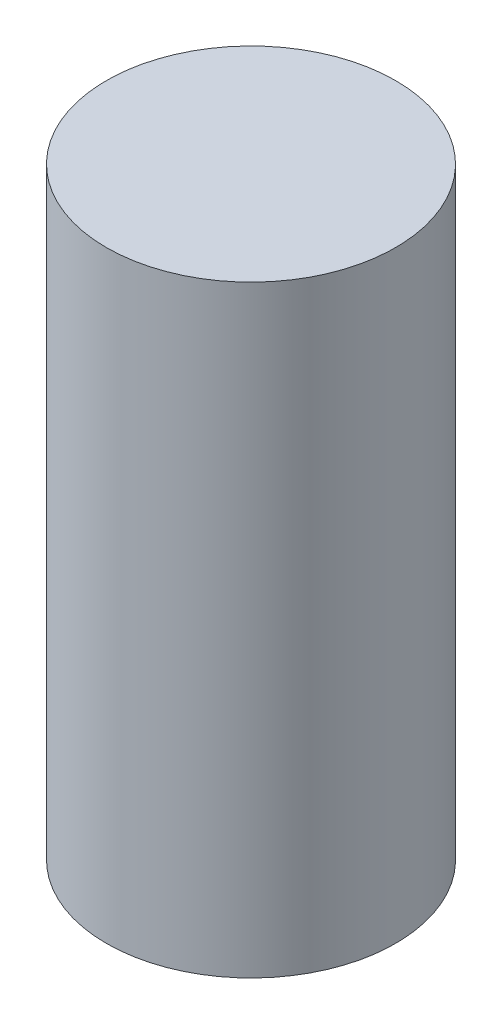
from build123d import *

# Parameters (mm, degrees)
SKETCH1_R           = 1.92
BOSS_EXTRUDE1_DEPTH = 8


with BuildPart() as part:
    # Sketch1 → Boss-Extrude1 (new body)
    with BuildSketch(Plane(origin=(0, 0, 0), x_dir=(1, 0, 0), z_dir=(0, 1, 0))):
        Circle(SKETCH1_R)
    extrude(amount=BOSS_EXTRUDE1_DEPTH)


solid = part.part
